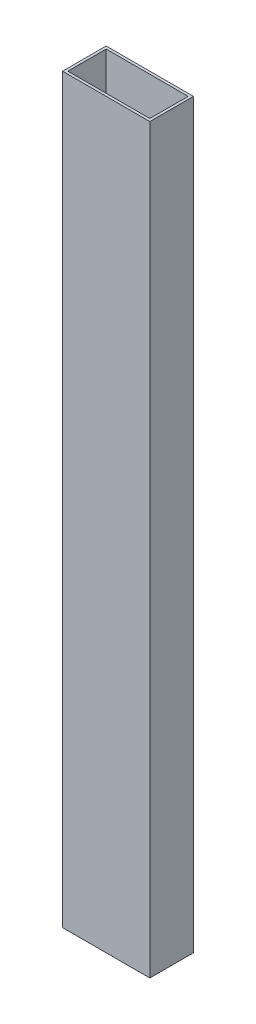
from build123d import *

# Parameters (mm, degrees)
SKETCH1_W           = 50.8
SKETCH1_H           = 25.4
SKETCH1_W_2         = 47.752
SKETCH1_H_2         = 22.352
BOSS_EXTRUDE1_DEPTH = 432.054


with BuildPart() as part:
    # Sketch1 → Boss-Extrude1 (new body)
    with BuildSketch(Plane(origin=(0, 0, 0), x_dir=(1, 0, 0), z_dir=(0, 1, 0))):
        with Locations((3.935211268, 0.357746479)):
            Rectangle(SKETCH1_W, SKETCH1_H)
        with Locations((3.935211268, 0.357746479)):
            Rectangle(SKETCH1_W_2, SKETCH1_H_2, mode=Mode.SUBTRACT)
    extrude(amount=BOSS_EXTRUDE1_DEPTH)


solid = part.part
